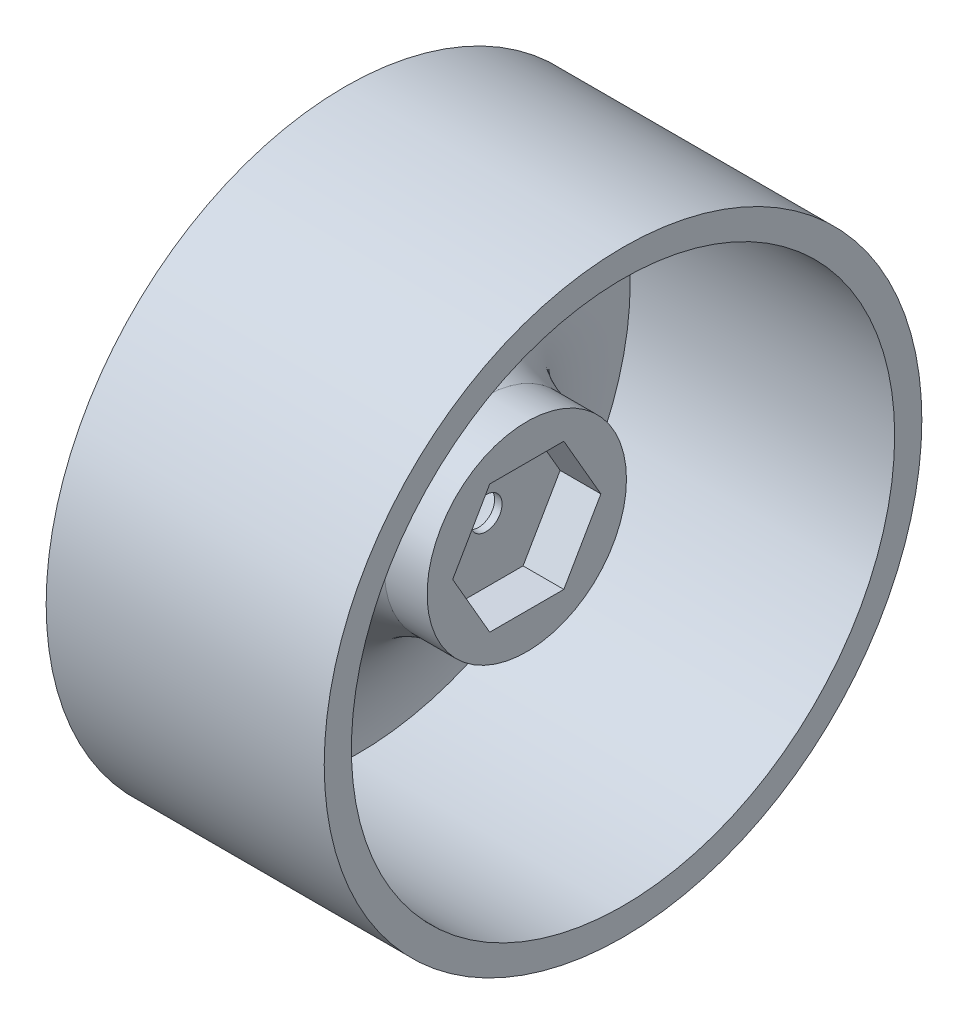
from build123d import *

# Parameters (mm, degrees)
CUT_EXTRUDE1_DEPTH = 3.81
SKETCH6_R          = 1.5
CUT_EXTRUDE2_DEPTH = 14.508000035


with BuildPart() as part:
    # Sketch2 → Main Revolve (revolve)
    with BuildSketch(Plane(origin=(0, 0, 0), x_dir=(1, 0, 0), z_dir=(0, 1, 0))):
        with BuildLine():
            Line((4, 8.05052812), (4, 9.32052812))
            Line((4, 9.32052812), (0, 9.32052812))
            add(Edge.make_bspline(
                [(-11.730000035, 25.4), (-11.939852155, 16.185984948), (-5.767624941, 10.573485752), (0, 9.32052812)],
                knots=[0, 0, 0, 0, 1, 1, 1, 1], degree=3))
            Line((-11.730000035, 25.4), (13.000000035, 25.4))
            Line((13.000000035, 25.4), (13.000000035, 27.94))
            Line((13.000000035, 27.94), (-13.000000035, 27.94))
            Line((-13.000000035, 27.94), (-13.000000035, 25.4))
            add(Edge.make_bspline(
                [(-0.508, 8.128), (-13.159061445, 7.336688862), (-13.000000035, 25.4)],
                knots=[0, 0, 0, 1, 1, 1], degree=2))
            Line((-0.508, 8.128), (-0.508, 0))
            Line((-0.508, 0), (4, 0))
            Line((4, 0), (4, 8.05052812))
        make_face()
    revolve(axis=Axis((4, 0, 0), (-1, 0, 0)))

    # Sketch5 → Cut-Extrude1 (cut)
    with BuildSketch(Plane(origin=(4, 0, 0), x_dir=(0, 0, -1), z_dir=(1, 0, 0))):
        Polygon((6.92820323, 0), (3.464101615, 6), (-3.464101615, 6), (-6.92820323, 0), (-3.464101615, -6), (3.464101615, -6), align=None)
    extrude(amount=-CUT_EXTRUDE1_DEPTH, mode=Mode.SUBTRACT)

    # Sketch6 → Cut-Extrude2 (cut, through all)
    with BuildSketch(Plane.ZY.offset(0.508)):
        Circle(SKETCH6_R)
    extrude(amount=-CUT_EXTRUDE2_DEPTH, mode=Mode.SUBTRACT)


solid = part.part
